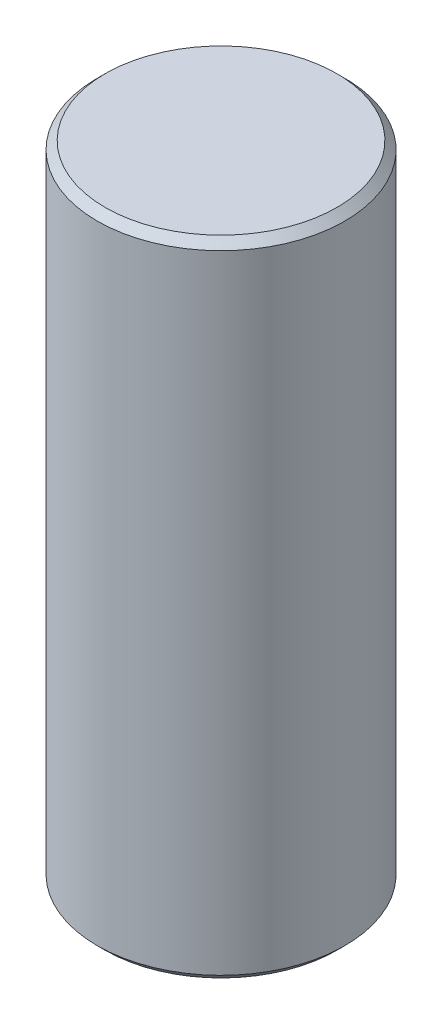
from build123d import *

# Parameters (mm, degrees)
SKETCH1_R           = 7.85
BOSS_EXTRUDE1_DEPTH = 40.8
CHAMFER1_SIZE       = 0.5


with BuildPart() as part:
    # Sketch1 → Boss-Extrude1 (new body)
    with BuildSketch(Plane(origin=(0, 0, 0), x_dir=(1, 0, 0), z_dir=(0, 1, 0))):
        Circle(SKETCH1_R)
    extrude(amount=BOSS_EXTRUDE1_DEPTH)

    # Chamfer1
    chamfer1_edges = [part.edges().sort_by_distance(p)[0] for p in [
        (-7.85, 0, 0),
        (-7.85, 40.8, 0),
    ]]
    chamfer(chamfer1_edges, length=CHAMFER1_SIZE)


solid = part.part
